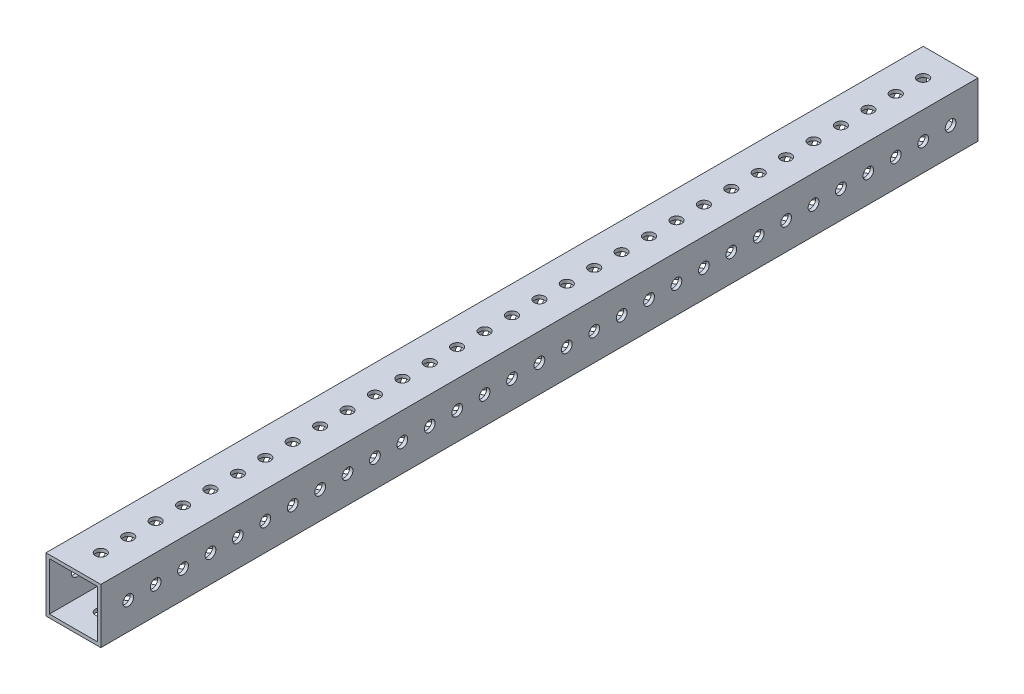
from build123d import *

# Parameters (mm, degrees)
SKETCH1_W           = 25.4
SKETCH1_H           = 25.4
SKETCH1_W_2         = 22.225
SKETCH1_H_2         = 22.225
BOSS_EXTRUDE1_DEPTH = 406.4
SKETCH2_R           = 2.4892
CUT_EXTRUDE1_DEPTH  = 26.4
SKETCH4_R           = 2.4892
CUT_EXTRUDE2_DEPTH  = 26.4


with BuildPart() as part:
    # Sketch1 → Boss-Extrude1 (new body)
    with BuildSketch(Plane.XY):
        with Locations((12.7, 12.7)):
            Rectangle(SKETCH1_W, SKETCH1_H)
        with Locations((12.7, 12.7)):
            Rectangle(SKETCH1_W_2, SKETCH1_H_2, mode=Mode.SUBTRACT)
    extrude(amount=BOSS_EXTRUDE1_DEPTH)

    # Sketch2 → Cut-Extrude1 (cut, through all)
    with BuildSketch(Plane(origin=(25.4, 0, 0), x_dir=(0, 0, -1), z_dir=(1, 0, 0))):
        with Locations((-393.7, 12.7)):
            Circle(SKETCH2_R)
        with Locations((-381, 12.7)):
            Circle(SKETCH2_R)
        with Locations((-368.3, 12.7)):
            Circle(SKETCH2_R)
        with Locations((-355.6, 12.7)):
            Circle(SKETCH2_R)
        with Locations((-342.9, 12.7)):
            Circle(SKETCH2_R)
        with Locations((-330.2, 12.7)):
            Circle(SKETCH2_R)
        with Locations((-317.5, 12.7)):
            Circle(SKETCH2_R)
        with Locations((-304.8, 12.7)):
            Circle(SKETCH2_R)
        with Locations((-292.1, 12.7)):
            Circle(SKETCH2_R)
        with Locations((-279.4, 12.7)):
            Circle(SKETCH2_R)
        with Locations((-266.7, 12.7)):
            Circle(SKETCH2_R)
        with Locations((-254, 12.7)):
            Circle(SKETCH2_R)
        with Locations((-241.3, 12.7)):
            Circle(SKETCH2_R)
        with Locations((-228.6, 12.7)):
            Circle(SKETCH2_R)
        with Locations((-215.9, 12.7)):
            Circle(SKETCH2_R)
        with Locations((-203.2, 12.7)):
            Circle(SKETCH2_R)
        with Locations((-190.5, 12.7)):
            Circle(SKETCH2_R)
        with Locations((-177.8, 12.7)):
            Circle(SKETCH2_R)
        with Locations((-165.1, 12.7)):
            Circle(SKETCH2_R)
        with Locations((-152.4, 12.7)):
            Circle(SKETCH2_R)
        with Locations((-139.7, 12.7)):
            Circle(SKETCH2_R)
        with Locations((-127, 12.7)):
            Circle(SKETCH2_R)
        with Locations((-114.3, 12.7)):
            Circle(SKETCH2_R)
        with Locations((-101.6, 12.7)):
            Circle(SKETCH2_R)
        with Locations((-88.9, 12.7)):
            Circle(SKETCH2_R)
        with Locations((-76.2, 12.7)):
            Circle(SKETCH2_R)
        with Locations((-63.5, 12.7)):
            Circle(SKETCH2_R)
        with Locations((-50.8, 12.7)):
            Circle(SKETCH2_R)
        with Locations((-38.1, 12.7)):
            Circle(SKETCH2_R)
        with Locations((-25.4, 12.7)):
            Circle(SKETCH2_R)
        with Locations((-12.7, 12.7)):
            Circle(SKETCH2_R)
    extrude(amount=-CUT_EXTRUDE1_DEPTH, mode=Mode.SUBTRACT)

    # Sketch4 → Cut-Extrude2 (cut, through all)
    with BuildSketch(Plane(origin=(0, 25.4, 0), x_dir=(1, 0, 0), z_dir=(0, 1, 0))):
        with Locations((12.7, -12.7)):
            Circle(SKETCH4_R)
        with Locations((12.7, -25.4)):
            Circle(SKETCH4_R)
        with Locations((12.7, -38.1)):
            Circle(SKETCH4_R)
        with Locations((12.7, -50.8)):
            Circle(SKETCH4_R)
        with Locations((12.7, -63.5)):
            Circle(SKETCH4_R)
        with Locations((12.7, -76.2)):
            Circle(SKETCH4_R)
        with Locations((12.7, -88.9)):
            Circle(SKETCH4_R)
        with Locations((12.7, -101.6)):
            Circle(SKETCH4_R)
        with Locations((12.7, -114.3)):
            Circle(SKETCH4_R)
        with Locations((12.7, -127)):
            Circle(SKETCH4_R)
        with Locations((12.7, -139.7)):
            Circle(SKETCH4_R)
        with Locations((12.7, -152.4)):
            Circle(SKETCH4_R)
        with Locations((12.7, -165.1)):
            Circle(SKETCH4_R)
        with Locations((12.7, -177.8)):
            Circle(SKETCH4_R)
        with Locations((12.7, -190.5)):
            Circle(SKETCH4_R)
        with Locations((12.7, -203.2)):
            Circle(SKETCH4_R)
        with Locations((12.7, -215.9)):
            Circle(SKETCH4_R)
        with Locations((12.7, -228.6)):
            Circle(SKETCH4_R)
        with Locations((12.7, -241.3)):
            Circle(SKETCH4_R)
        with Locations((12.7, -254)):
            Circle(SKETCH4_R)
        with Locations((12.7, -266.7)):
            Circle(SKETCH4_R)
        with Locations((12.7, -279.4)):
            Circle(SKETCH4_R)
        with Locations((12.7, -292.1)):
            Circle(SKETCH4_R)
        with Locations((12.7, -304.8)):
            Circle(SKETCH4_R)
        with Locations((12.7, -317.5)):
            Circle(SKETCH4_R)
        with Locations((12.7, -330.2)):
            Circle(SKETCH4_R)
        with Locations((12.7, -342.9)):
            Circle(SKETCH4_R)
        with Locations((12.7, -355.6)):
            Circle(SKETCH4_R)
        with Locations((12.7, -368.3)):
            Circle(SKETCH4_R)
        with Locations((12.7, -381)):
            Circle(SKETCH4_R)
        with Locations((12.7, -393.7)):
            Circle(SKETCH4_R)
    extrude(amount=-CUT_EXTRUDE2_DEPTH, mode=Mode.SUBTRACT)


solid = part.part
